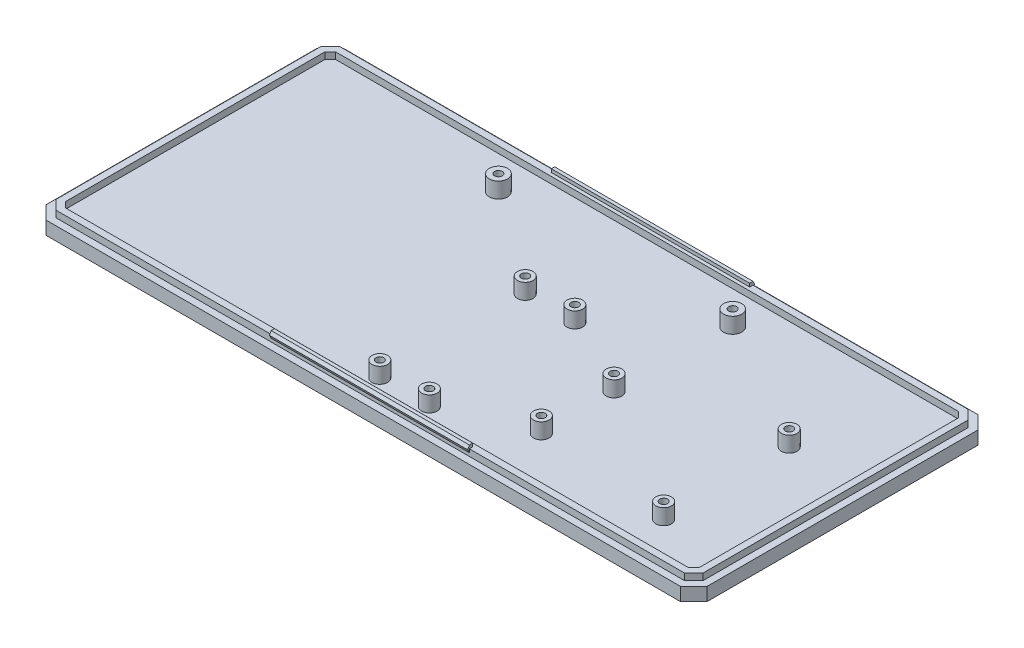
from build123d import *

# Parameters (mm, degrees)
SKETCH1_W                 = 254
SKETCH1_H                 = 114.3
BOSS_EXTRUDE1_DEPTH       = 5.08
CHAMFER1_SIZE             = 5.08
BOSS_EXTRUDE3_START       = -127
BOSS_EXTRUDE3_DEPTH       = 38.1
BOSS_EXTRUDE4_DEPTH       = 2.54
SKETCH6_R                 = 3
BOSS_EXTRUDE5_DEPTH       = 6
SKETCH12_R                = 3
SKETCH12_R_2              = 3.5
BOSS_EXTRUDE7_DEPTH       = 6
F_3_0MM_DOWEL_HOLE1_D     = 3
F_3_0MM_DOWEL_HOLE1_DEPTH = 5.08


with BuildPart() as part:
    # Sketch1 → Boss-Extrude1 (new body)
    with BuildSketch(Plane(origin=(0, 0, 0), x_dir=(1, 0, 0), z_dir=(0, 1, 0))):
        with Locations((-127, 57.15)):
            Rectangle(SKETCH1_W, SKETCH1_H)
    extrude(amount=BOSS_EXTRUDE1_DEPTH)

    # Chamfer1
    chamfer1_edges = [part.edges().sort_by_distance(p)[0] for p in [
        (0, 2.54, 0),
        (-254, 2.54, 0),
        (-254, 2.54, -114.3),
        (0, 2.54, -114.3),
    ]]
    chamfer(chamfer1_edges, length=CHAMFER1_SIZE)

    # Sketch3 → Boss-Extrude3 (add, symmetric)
    with BuildSketch(Plane(origin=(0, 0, 0), x_dir=(0, 0, -1), z_dir=(1, 0, 0)).offset(BOSS_EXTRUDE3_START)):
        Polygon((2.667, 5.08), (2.667, 6.35), (2.032, 7.62), (2.667, 8.89), (3.937, 8.89), (3.937, 5.08), align=None)
    boss_extrude3 = extrude(amount=BOSS_EXTRUDE3_DEPTH, both=True)

    # Mirror1: Boss-Extrude3 across plane
    add(boss_extrude3.mirror(Plane.XY.offset(-57.15)))

    # Sketch4 → Boss-Extrude4 (add)
    with BuildSketch(Plane(origin=(0, 5.08, 0), x_dir=(1, 0, 0), z_dir=(0, 1, 0))):
        Polygon((-6.184707571, 111.633), (-247.815292429, 111.633), (-251.333, 108.115292429), (-251.333, 6.184707571), (-247.815292429, 2.667), (-6.184707571, 2.667), (-2.667, 6.184707571), (-2.667, 108.115292429), align=None)
        Polygon((-7.247331044, 109.0676), (-246.752668956, 109.0676), (-248.7676, 107.052668956), (-248.7676, 7.247331044), (-246.752668956, 5.2324), (-7.247331044, 5.2324), (-5.2324, 7.247331044), (-5.2324, 107.052668956), align=None, mode=Mode.SUBTRACT)
    extrude(amount=BOSS_EXTRUDE4_DEPTH)

    # Sketch6 → Boss-Extrude5 (add)
    with BuildSketch(Plane(origin=(0, 5.08, 0), x_dir=(1, 0, 0), z_dir=(0, 1, 0))):
        with Locations((-30.6324, 67.31)):
            Circle(SKETCH6_R)
        with Locations((-30.6324, 19.05)):
            Circle(SKETCH6_R)
        with Locations((-82.7024, 52.07)):
            Circle(SKETCH6_R)
        with Locations((-82.7024, 24.13)):
            Circle(SKETCH6_R)
    extrude(amount=BOSS_EXTRUDE5_DEPTH)

    # Sketch12 → Boss-Extrude7 (add)
    with BuildSketch(Plane(origin=(0, 5.08, 0), x_dir=(1, 0, 0), z_dir=(0, 1, 0))):
        with Locations((-132.2324, 67.4624)):
            Circle(SKETCH12_R)
        with Locations((-132.2324, 11.5824)):
            Circle(SKETCH12_R)
        with Locations((-113.1824, 67.4624)):
            Circle(SKETCH12_R)
        with Locations((-113.1824, 11.5824)):
            Circle(SKETCH12_R)
        with Locations((-81.4324, 96.3676)):
            Circle(SKETCH12_R_2)
        with Locations((-171.4324, 96.3676)):
            Circle(SKETCH12_R_2)
    extrude(amount=BOSS_EXTRUDE7_DEPTH)

    # Ø3.0mm Dowel Hole1
    with Locations(Plane(origin=(0, 11.08, 0), x_dir=(1, 0, 0), z_dir=(0, 1, 0))):
        with Locations((-82.7024, 24.13), (-82.7024, 52.07), (-30.6324, 67.31), (-30.6324, 19.05), (-132.2324, 11.5824), (-113.1824, 11.5824), (-171.4324, 96.3676), (-132.2324, 67.4624), (-113.1824, 67.4624), (-81.4324, 96.3676)):
            Hole(F_3_0MM_DOWEL_HOLE1_D / 2, depth=F_3_0MM_DOWEL_HOLE1_DEPTH)


solid = part.part
